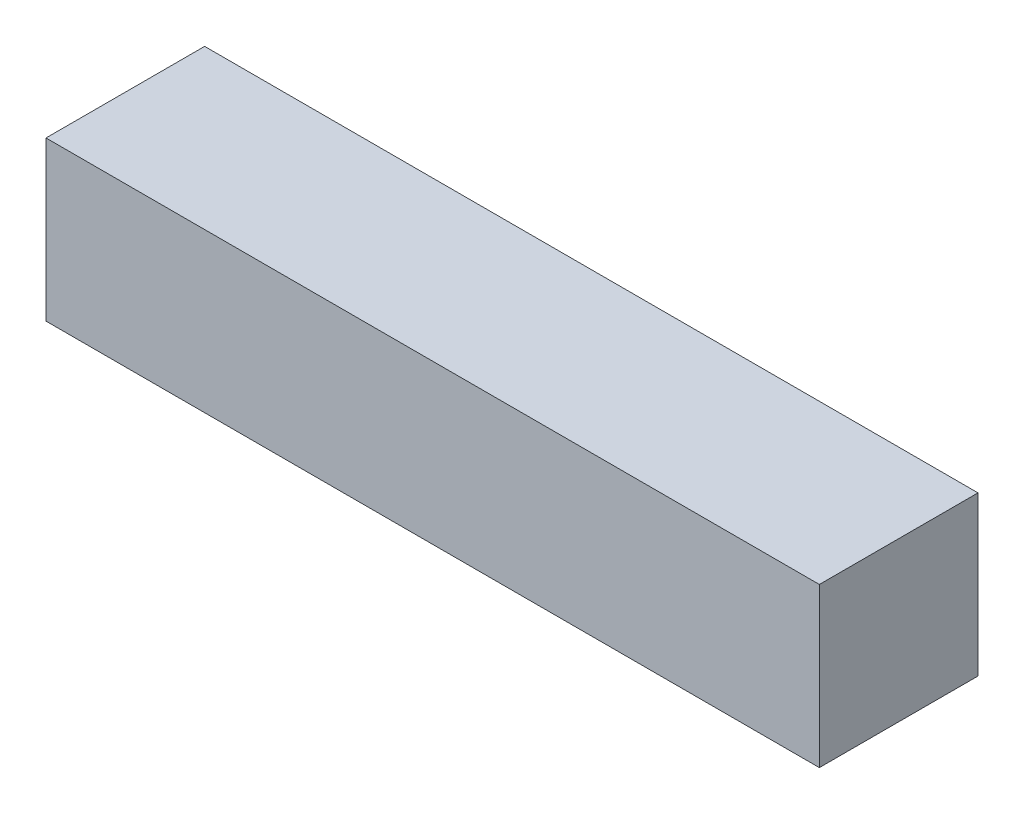
from build123d import *

# Parameters (mm, degrees)
SKETCH1_W           = 1170
SKETCH1_H           = 240
BOSS_EXTRUDE1_DEPTH = 120


with BuildPart() as part:
    # Sketch1 → Boss-Extrude1 (new, symmetric)
    with BuildSketch(Plane.XY):
        with Locations((0, 120)):
            Rectangle(SKETCH1_W, SKETCH1_H)
    extrude(amount=BOSS_EXTRUDE1_DEPTH, both=True)


solid = part.part
